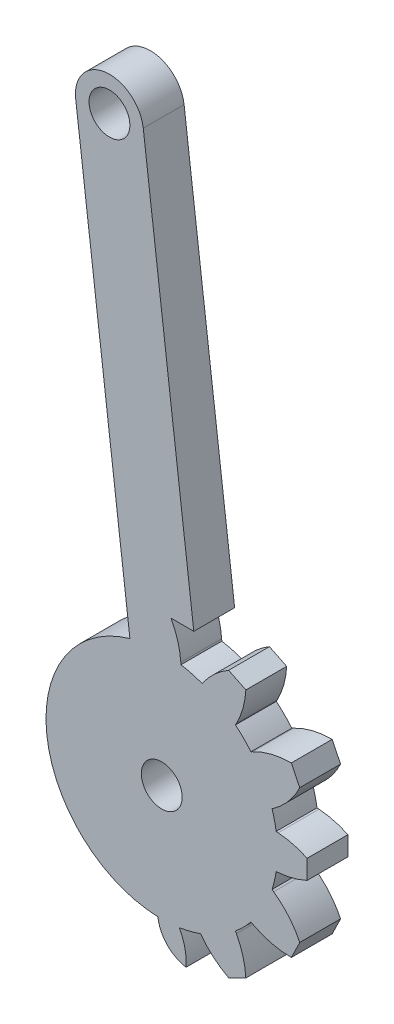
from build123d import *

# Parameters (mm, degrees)
SKETCH1_R           = 1.5
BOSS_EXTRUDE1_DEPTH = 3


with BuildPart() as part:
    # Sketch1 → Boss-Extrude1 (new body)
    with BuildSketch(Plane.XY.offset(1.9)):
        with BuildLine():
            Line((-6.319804534, 40.514327491), (-2.33662546, 8.172526015))
            ThreePointArc((-2.33662546, 8.172526015), (-8.436254395, -1.03904369), (-0.283752271, -8.495262483))
            ThreePointArc((-0.283752271, -8.495262483), (0.387258031, -9.932027081), (1.787569077, -10.676121371))
            ThreePointArc((1.787569077, -10.676121371), (1.706000613, -9.502192185), (1.28944453, -8.401626795))
            ThreePointArc((1.28944453, -8.401626795), (2.079332338, -8.241745994), (2.850528183, -8.007776788))
            ThreePointArc((2.850528183, -8.007776788), (3.779603703, -9.013165462), (4.91238571, -9.781795823))
            Line((4.91238571, -9.781795823), (6.178855756, -9.161994546))
            ThreePointArc((6.178855756, -9.161994546), (5.965894349, -7.885306169), (5.484085843, -6.683995909))
            Line((5.484085843, -6.683995909), (5.414116812, -6.552658937))
            ThreePointArc((5.414116812, -6.552658937), (6.01040764, -6.01040764), (6.552658937, -5.414116812))
            Line((6.552658937, -5.414116812), (6.683995909, -5.484085843))
            ThreePointArc((6.683995909, -5.484085843), (8.057590144, -6.011450066), (9.518230762, -6.188659346))
            Line((9.518230762, -6.188659346), (10.138032038, -4.922189299))
            ThreePointArc((10.138032038, -4.922189299), (9.323454041, -3.667986658), (8.224003874, -2.65419629))
            Line((8.224003874, -2.65419629), (8.102883181, -2.567739114))
            ThreePointArc((8.102883181, -2.567739114), (8.278718168, -1.926869349), (8.403949047, -1.274221493))
            Line((8.403949047, -1.274221493), (8.552369893, -1.263436399))
            ThreePointArc((8.552369893, -1.263436399), (9.641452494, -1.082458564), (10.678939324, -0.705))
            Line((10.678939324, -0.705), (10.678939324, 0.705))
            ThreePointArc((10.678939324, 0.705), (9.641452494, 1.082458564), (8.552369893, 1.263436399))
            Line((8.552369893, 1.263436399), (8.403949047, 1.274221493))
            ThreePointArc((8.403949047, 1.274221493), (8.278718168, 1.926869349), (8.102883181, 2.567739114))
            Line((8.102883181, 2.567739114), (8.224003874, 2.65419629))
            ThreePointArc((8.224003874, 2.65419629), (9.323454041, 3.667986658), (10.138032038, 4.922189299))
            Line((10.138032038, 4.922189299), (9.518230762, 6.188659346))
            ThreePointArc((9.518230762, 6.188659346), (8.057590144, 6.011450066), (6.683995909, 5.484085843))
            Line((6.683995909, 5.484085843), (6.552658937, 5.414116812))
            ThreePointArc((6.552658937, 5.414116812), (6.01040764, 6.01040764), (5.414116812, 6.552658937))
            Line((5.414116812, 6.552658937), (5.484085843, 6.683995909))
            ThreePointArc((5.484085843, 6.683995909), (5.965894349, 7.885306169), (6.178855756, 9.161994546))
            Line((6.178855756, 9.161994546), (4.91238571, 9.781795823))
            ThreePointArc((4.91238571, 9.781795823), (3.893417709, 9.032482418), (3.054167872, 8.08621286))
            Line((3.054167872, 8.08621286), (2.967710696, 7.965092167))
            ThreePointArc((2.967710696, 7.965092167), (2.199961883, 8.210369523), (1.41243323, 8.381827508))
            Line((1.41243323, 8.381827508), (1.401648136, 8.530248353))
            ThreePointArc((1.401648136, 8.530248353), (1.171954356, 9.79405056), (0.678518537, 10.980000113))
            Line((0.678518537, 10.980000113), (2.3553868, 10.980000113))
            Line((2.3553868, 10.980000113), (-1.357298788, 41.125503992))
            ThreePointArc((-1.357298788, 41.125503992), (-4.144139911, 43.301168615), (-6.319804534, 40.514327491))
        make_face()
        with Locations((-3.838551661, 40.819915742)):
            Circle(SKETCH1_R, mode=Mode.SUBTRACT)
        Circle(SKETCH1_R, mode=Mode.SUBTRACT)
    extrude(amount=-BOSS_EXTRUDE1_DEPTH)


solid = part.part
